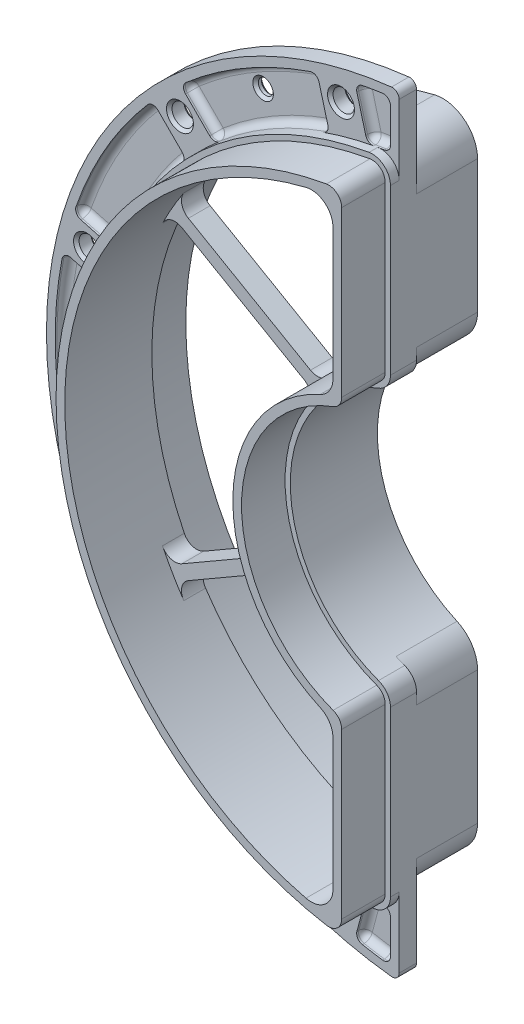
from build123d import *

# Parameters (mm, degrees)
EXTRUDE_THIN1_DEPTH            = 16
FILLET1_R                      = 5
FILLET2_R                      = 4.2
CUT_EXTRUDE_THIN1_DEPTH        = 10
BOSS_EXTRUDE1_START            = -2
BOSS_EXTRUDE1_DEPTH            = 4
CUT_EXTRUDE2_DEPTH             = 2
BOSS_EXTRUDE2_DEPTH            = 2
CIRPATTERN1_COUNT              = 6
CIRPATTERN1_ANGLE              = 150
F_8_CLEARANCE_HOLE1_AT_2_COUNT = 2
F_8_CLEARANCE_HOLE1_AT_2_PITCH = 42.705142442
F_8_CLEARANCE_HOLE1_AT_3_COUNT = 2
F_8_CLEARANCE_HOLE1_AT_3_PITCH = 82.5
F_8_CLEARANCE_HOLE1_AT_4_COUNT = 2
F_8_CLEARANCE_HOLE1_AT_4_PITCH = 116.672618896
F_8_CLEARANCE_HOLE1_AT_5_COUNT = 2
F_8_CLEARANCE_HOLE1_AT_5_PITCH = 142.894191624
F_8_CLEARANCE_HOLE1_AT_6_COUNT = 2
F_8_CLEARANCE_HOLE1_AT_6_PITCH = 159.377761338
FILLET3_R                      = 1.5875
FILLET4_R                      = 1.5875
EXTRUDE_THIN2_DEPTH            = 14
FILLET5_R                      = 5
FILLET6_R                      = 8
CUT_EXTRUDE1_DEPTH             = 10
BOSS_EXTRUDE3_DEPTH            = 5
FILLET7_R                      = 3.175


with BuildPart() as part:
    # Sketch1 → Extrude-Thin1 (new body)
    with BuildSketch(Plane.XY):
        with BuildLine():
            Line((-8, -29.949958264), (-8, -75.577774511))
            ThreePointArc((-8, -75.577774511), (-76, 0), (-8, 75.577774511))
            Line((-8, 75.577774511), (-8, 29.949958264))
            ThreePointArc((-8, 29.949958264), (-31, 0), (-8, -29.949958264))
        make_face()
        with BuildLine():
            Line((-11.2, -32.314083617), (-11.2, -71.933302441))
            ThreePointArc((-11.2, -71.933302441), (-72.8, 0), (-11.2, 71.933302441))
            Line((-11.2, 71.933302441), (-11.2, 32.314083617))
            ThreePointArc((-11.2, 32.314083617), (-34.2, 0), (-11.2, -32.314083617))
        make_face(mode=Mode.SUBTRACT)
    extrude(amount=EXTRUDE_THIN1_DEPTH)

    # Fillet1
    fillet1_edges = [part.edges().sort_by_distance(p)[0] for p in [
        (-11.2, 71.933302441, 8),
        (-11.2, -71.933302441, 8),
        (-11.2, -32.314083617, 8),
        (-11.2, 32.314083617, 8),
    ]]
    fillet(fillet1_edges, radius=FILLET1_R)

    # Fillet2
    fillet2_edges = [part.edges().sort_by_distance(p)[0] for p in [
        (-8, 75.577774511, 8),
        (-8, 29.949958264, 8),
        (-8, -29.949958264, 8),
        (-8, -75.577774511, 8),
    ]]
    fillet(fillet2_edges, radius=FILLET2_R)

    # Sketch2 → Cut-Extrude-Thin1 (cut)
    with BuildSketch(Plane.XY.offset(16)):
        with BuildLine():
            Line((-8, 33.018176812), (-8, 70.75591848))
            ThreePointArc((-8, 70.75591848), (-9.494203066, 73.968186052), (-12.913649025, 74.894844074))
            ThreePointArc((-12.913649025, 74.894844074), (-76, 0), (-12.913649025, -74.894844074))
            ThreePointArc((-12.913649025, -74.894844074), (-9.494203066, -73.968186052), (-8, -70.75591848))
            Line((-8, -70.75591848), (-8, -33.018176812))
            ThreePointArc((-8, -33.018176812), (-8.753707526, -30.617537693), (-10.744318182, -29.078507988))
            ThreePointArc((-10.744318182, -29.078507988), (-31, 0), (-10.744318182, 29.078507988))
            ThreePointArc((-10.744318182, 29.078507988), (-8.753707526, 30.617537693), (-8, 33.018176812))
        make_face()
        with BuildLine():
            Line((-9.2, 33.018176812), (-9.2, 70.75591848))
            ThreePointArc((-9.2, 70.75591848), (-10.267287904, 73.050395317), (-12.709749304, 73.712293904))
            ThreePointArc((-12.709749304, 73.712293904), (-74.8, 0), (-12.709749304, -73.712293904))
            ThreePointArc((-12.709749304, -73.712293904), (-10.267287904, -73.050395317), (-9.2, -70.75591848))
            Line((-9.2, -70.75591848), (-9.2, -33.018176812))
            ThreePointArc((-9.2, -33.018176812), (-9.738362518, -31.303434584), (-11.160227273, -30.204127652))
            ThreePointArc((-11.160227273, -30.204127652), (-32.2, 0), (-11.160227273, 30.204127652))
            ThreePointArc((-11.160227273, 30.204127652), (-9.738362518, 31.303434584), (-9.2, 33.018176812))
        make_face(mode=Mode.SUBTRACT)
    extrude(amount=-CUT_EXTRUDE_THIN1_DEPTH, mode=Mode.SUBTRACT)



with BuildPart() as body_2:
    # Sketch3 → Boss-Extrude1 (new body)
    with BuildSketch(Plane.XY.offset(6).offset(BOSS_EXTRUDE1_START)):
        with BuildLine():
            Line((-8, -70.75591848), (-8, -88.639720216))
            ThreePointArc((-8, -88.639720216), (-89, 0), (-8, 88.639720216))
            Line((-8, 88.639720216), (-8, 70.75591848))
            ThreePointArc((-8, 70.75591848), (-9.494203066, 73.968186052), (-12.913649025, 74.894844074))
            ThreePointArc((-12.913649025, 74.894844074), (-76, 0), (-12.913649025, -74.894844074))
            ThreePointArc((-12.913649025, -74.894844074), (-9.494203066, -73.968186052), (-8, -70.75591848))
        make_face()
    extrude(amount=-BOSS_EXTRUDE1_DEPTH)

    # Sketch9 → Cut-Extrude2 (cut)
    with BuildSketch(Plane.XY.offset(4)):
        with BuildLine():
            Line((-10, 75.339232807), (-10, 86.423376467))
            ThreePointArc((-10, 86.423376467), (-87, 0), (-10, -86.423376467))
            Line((-10, -86.423376467), (-10, -75.339232807))
            ThreePointArc((-10, -75.339232807), (-76, 0), (-10, 75.339232807))
        make_face()
    extrude(amount=-CUT_EXTRUDE2_DEPTH, mode=Mode.SUBTRACT)


with BuildPart() as part_1:
    add(part.part)

    add(body_2.part)  # Boss-Extrude2 merges body 2
    # Sketch10 → Boss-Extrude2 (add)
    with BuildSketch(Plane.XY.offset(4)):
        Polygon((-27.058037426, -83.595305554), (-18.364704989, -85.92467696), (-15.129466926, -73.850604131), (-23.822799362, -71.521232725), align=None)
    boss_extrude2 = extrude(amount=-BOSS_EXTRUDE2_DEPTH)

    # CirPattern1: Boss-Extrude2 ×6 about axis
    cirpattern1_axis = Axis((0, 0, 0), (0, 0, -1))
    for i in range(1, CIRPATTERN1_COUNT):
        add(boss_extrude2.rotate(cirpattern1_axis, i * CIRPATTERN1_ANGLE / (CIRPATTERN1_COUNT - 1)))

    # Sketch12 → #8 Clearance Hole1 (revolve, cut)
    with BuildSketch(Plane(origin=(-21.352571221, -79.688880669, 4), x_dir=(0, -1, 0), z_dir=(1, 0, 0))):
        Polygon((0, 0), (0, 4), (3.09245, 4), (2.45745, 3.365), (2.45745, 0.635), (3.09245, 0), align=None)
    f_8_clearance_hole1 = revolve(axis=Axis((-21.352571221, -79.688880669, 10.35), (0, 0, -1)), mode=Mode.SUBTRACT)

    # #8 Clearance Hole1 at 2: #8 Clearance Hole1 ×2
    with Locations(*[Vector(-0.866025404, 0.5, 0) * (i * F_8_CLEARANCE_HOLE1_AT_2_PITCH) for i in range(1, F_8_CLEARANCE_HOLE1_AT_2_COUNT)]):
        add(f_8_clearance_hole1, mode=Mode.SUBTRACT)

    # #8 Clearance Hole1 at 3: #8 Clearance Hole1 ×2
    with Locations(*[Vector(-0.707106781, 0.707106781, 0) * (i * F_8_CLEARANCE_HOLE1_AT_3_PITCH) for i in range(1, F_8_CLEARANCE_HOLE1_AT_3_COUNT)]):
        add(f_8_clearance_hole1, mode=Mode.SUBTRACT)

    # #8 Clearance Hole1 at 4: #8 Clearance Hole1 ×2
    with Locations(*[Vector(-0.5, 0.866025404, 0) * (i * F_8_CLEARANCE_HOLE1_AT_4_PITCH) for i in range(1, F_8_CLEARANCE_HOLE1_AT_4_COUNT)]):
        add(f_8_clearance_hole1, mode=Mode.SUBTRACT)

    # #8 Clearance Hole1 at 5: #8 Clearance Hole1 ×2
    with Locations(*[Vector(-0.258819045, 0.965925826, 0) * (i * F_8_CLEARANCE_HOLE1_AT_5_PITCH) for i in range(1, F_8_CLEARANCE_HOLE1_AT_5_COUNT)]):
        add(f_8_clearance_hole1, mode=Mode.SUBTRACT)

    # #8 Clearance Hole1 at 6: #8 Clearance Hole1 ×2
    with Locations(*[(0, i * F_8_CLEARANCE_HOLE1_AT_6_PITCH, 0) for i in range(1, F_8_CLEARANCE_HOLE1_AT_6_COUNT)]):
        add(f_8_clearance_hole1, mode=Mode.SUBTRACT)

    # Fillet3
    fillet3_edges = [part_1.edges().sort_by_distance(p)[0] for p in [
        (-15.289070108, -74.446251317, 3),
        (-23.982402545, -72.116879912, 3),
        (-16.714759729, -79.766997419, 2),
        (-25.408092166, -77.437626013, 2),
        (-26.833781787, -82.758372114, 3),
        (-18.14044935, -85.08774352, 3),
        (-43.5, -75.344210129, 2),
        (-10, 86.423376467, 3),
        (-12.652415608, 74.939418061, 2),
        (-12.652415608, -74.939418061, 2),
        (-10, -75.339232807, 3),
        (-14.086064079, -85.852098395, 2),
        (-10, 80.881304637, 2),
        (-10, 75.339232807, 3),
        (-10, -80.881304637, 2),
        (-10, -86.423376467, 3),
        (-75.344210129, -43.5, 2),
        (-58.253961733, -64.617922764, 3),
        (-64.617922764, -58.253961733, 3),
        (-38, -65.817930688, 2),
        (-56.827809803, -50.463848773, 3),
        (-50.463848773, -56.827809803, 3),
        (-60.722866284, -54.358905253, 2),
        (-54.358905253, -60.722866284, 2),
        (-65.817930688, -38, 2),
        (-87, 0, 2),
        (-77.437626013, -25.408092166, 2),
        (-79.766997419, -16.714759729, 2),
        (-85.08774352, -18.14044935, 3),
        (-82.758372114, -26.833781787, 3),
        (-74.446251317, -15.289070108, 3),
        (-72.116879912, -23.982402545, 3),
        (-76, 0, 2),
        (-75.344210129, 43.5, 2),
        (-79.766997419, 16.714759729, 2),
        (-77.437626013, 25.408092166, 2),
        (-82.758372114, 26.833781787, 3),
        (-85.08774352, 18.14044935, 3),
        (-72.116879912, 23.982402545, 3),
        (-74.446251317, 15.289070108, 3),
        (-65.817930688, 38, 2),
        (-43.5, 75.344210129, 2),
        (-60.722866284, 54.358905253, 2),
        (-54.358905253, 60.722866284, 2),
        (-58.253961733, 64.617922764, 3),
        (-64.617922764, 58.253961733, 3),
        (-50.463848773, 56.827809803, 3),
        (-56.827809803, 50.463848773, 3),
        (-38, 65.817930688, 2),
        (-14.086064079, 85.852098395, 2),
        (-25.408092166, 77.437626013, 2),
        (-16.714759729, 79.766997419, 2),
        (-18.14044935, 85.08774352, 3),
        (-26.833781787, 82.758372114, 3),
        (-15.289070108, 74.446251317, 3),
        (-23.982402545, 72.116879912, 3),
    ]]
    fillet(fillet3_edges, radius=FILLET3_R)

    # Fillet4
    fillet4_edges = [part_1.edges().sort_by_distance(p)[0] for p in [
        (-8, -88.639720216, 2),
        (-8, 88.639720216, 2),
    ]]
    fillet(fillet4_edges, radius=FILLET4_R)


with BuildPart() as body_2_2:
    # Sketch17 → Extrude-Thin2 (new body)
    with BuildSketch(Plane(origin=(0, 0, 0), x_dir=(-1, 0, 0), z_dir=(0, 0, -1))):
        with BuildLine():
            Line((8, 75.577774511), (8, 29.949958264))
            ThreePointArc((8, 29.949958264), (31, 0), (8, -29.949958264))
            Line((8, -29.949958264), (8, -75.577774511))
            ThreePointArc((8, -75.577774511), (76, 0), (8, 75.577774511))
        make_face()
        with BuildLine():
            Line((11.2, 71.933302441), (11.2, 32.314083617))
            ThreePointArc((11.2, 32.314083617), (34.2, 0), (11.2, -32.314083617))
            Line((11.2, -32.314083617), (11.2, -71.933302441))
            ThreePointArc((11.2, -71.933302441), (72.8, 0), (11.2, 71.933302441))
        make_face(mode=Mode.SUBTRACT)
    extrude(amount=EXTRUDE_THIN2_DEPTH)

    # Fillet5
    fillet5_edges = [body_2_2.edges().sort_by_distance(p)[0] for p in [
        (-11.2, -71.933302441, -7),
        (-11.2, 71.933302441, -7),
        (-11.2, 32.314083617, -7),
        (-11.2, -32.314083617, -7),
    ]]
    fillet(fillet5_edges, radius=FILLET5_R)

    # Fillet6
    fillet6_edges = [body_2_2.edges().sort_by_distance(p)[0] for p in [
        (-8, -75.577774511, -7),
        (-8, -29.949958264, -7),
        (-8, 29.949958264, -7),
        (-8, 75.577774511, -7),
    ]]
    fillet(fillet6_edges, radius=FILLET6_R)


with BuildPart() as part_2:
    add(part_1.part)

    # Combine1: union body 2 2
    add(body_2_2.part)

    # Sketch7 → Cut-Extrude1 (cut)
    with BuildSketch(Plane(origin=(0, 0, -14), x_dir=(-1, 0, 0), z_dir=(0, 0, -1))):
        with BuildLine():
            Line((9, 66.090846567), (9, 35.566838488))
            ThreePointArc((9, 35.566838488), (10.121966141, 31.765691562), (13.128205128, 29.183046964))
            ThreePointArc((13.128205128, 29.183046964), (32, 0), (13.128205128, -29.183046964))
            ThreePointArc((13.128205128, -29.183046964), (10.121966141, -31.765691562), (9, -35.566838488))
            Line((9, -35.566838488), (9, -66.090846567))
            ThreePointArc((9, -66.090846567), (11.671571403, -71.592183303), (17.647058824, -72.894316067))
            ThreePointArc((17.647058824, -72.894316067), (75, 0), (17.647058824, 72.894316067))
            ThreePointArc((17.647058824, 72.894316067), (11.671571403, 71.592183303), (9, 66.090846567))
        make_face()
    extrude(amount=-CUT_EXTRUDE1_DEPTH, mode=Mode.SUBTRACT)

    # Sketch14 → #29 (0.136) Diameter Hole1 (revolve, cut)
    with BuildSketch(Plane(origin=(-41.25, -71.447095812, 2), x_dir=(0, -1, 0), z_dir=(1, 0, 0))):
        Polygon((0, 0), (0, 2), (2.3622, 2), (1.7272, 1.365), (1.7272, 0.635), (2.3622, 0), align=None)
    f_29_0_136_diameter_hole1 = revolve(axis=Axis((-41.25, -71.447095812, 8.35), (0, 0, -1)), mode=Mode.SUBTRACT)

    # Mirror1: #29 (0.136) Diameter Hole1 across plane
    add(f_29_0_136_diameter_hole1.mirror(Plane.ZX), mode=Mode.SUBTRACT)

    # Sketch18 → Boss-Extrude3 (add)
    with BuildSketch(Plane.XY.offset(-4)):
        with BuildLine():
            Line((-62.283265027, -37.691310637), (-28.839567418, -18.38258282))
            ThreePointArc((-28.839567418, -18.38258282), (-29.618068809, -17.1), (-30.339567418, -15.784506608))
            Line((-30.339567418, -15.784506608), (-63.783265027, -35.093234426))
            ThreePointArc((-63.783265027, -35.093234426), (-63.046649396, -36.4), (-62.283265027, -37.691310637))
        make_face()
    boss_extrude3 = extrude(amount=BOSS_EXTRUDE3_DEPTH)

    # Mirror2: Boss-Extrude3 across plane
    add(boss_extrude3.mirror(Plane.ZX))

    # Fillet7
    fillet7_edges = [part_2.edges().sort_by_distance(p)[0] for p in [
        (-63.783265027, -35.093234426, -1.5),
        (-62.283265027, -37.691310637, -1.5),
        (-28.839567418, -18.38258282, -1.5),
        (-30.339567418, -15.784506608, -1.5),
        (-62.283265027, 37.691310637, -1.5),
        (-63.783265027, 35.093234426, -1.5),
        (-30.339567418, 15.784506608, -1.5),
        (-28.839567418, 18.38258282, -1.5),
    ]]
    fillet(fillet7_edges, radius=FILLET7_R)


solid = part_2.part
